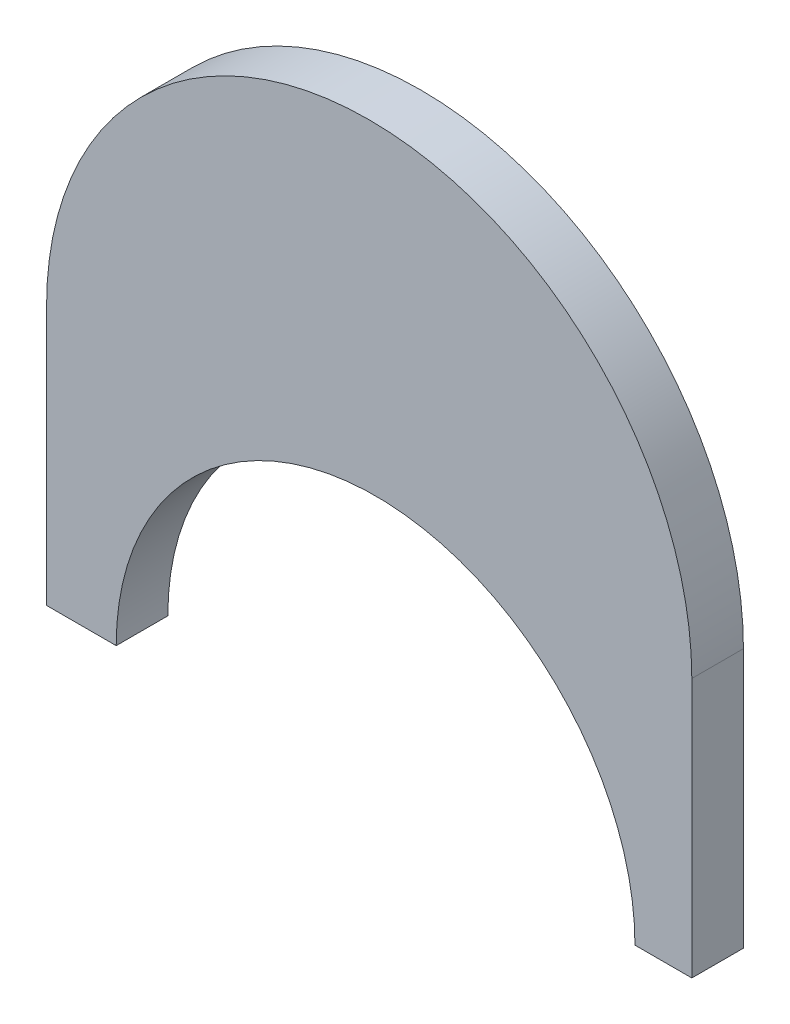
from build123d import *

# Parameters (mm, degrees)
BOSS_EXTRUDE1_DEPTH = 5.08


with BuildPart() as part:
    # Sketch1 → Boss-Extrude1 (new body)
    with BuildSketch(Plane.XY):
        with BuildLine():
            Line((0.629745632, 0.007769029), (-31.749999049, 0.007769029))
            Line((-31.749999049, 0.007769029), (-31.749999049, -25.519230971))
            Line((-31.749999049, -25.519230971), (-24.897254295, -25.519230971))
            ThreePointArc((-24.897254295, -25.519230971), (-17.420569124, -7.468916193), (0.629745632, 0.007769029))
        make_face()
        with BuildLine():
            Line((31.749999049, 0.007769029), (0.629745632, 0.007769029))
            ThreePointArc((0.629745632, 0.007769029), (18.680060482, -7.468916142), (26.156745705, -25.519230971))
            Line((26.156745705, -25.519230971), (31.749999049, -25.519230971))
            Line((31.749999049, -25.519230971), (31.749999049, 0.007769029))
        make_face()
        with BuildLine():
            ThreePointArc((-31.749999049, 0.007769029), (0, 31.75), (31.749999049, 0.007769029))
            Line((31.749999049, 0.007769029), (-31.749999049, 0.007769029))
        make_face()
    extrude(amount=-BOSS_EXTRUDE1_DEPTH)


solid = part.part
